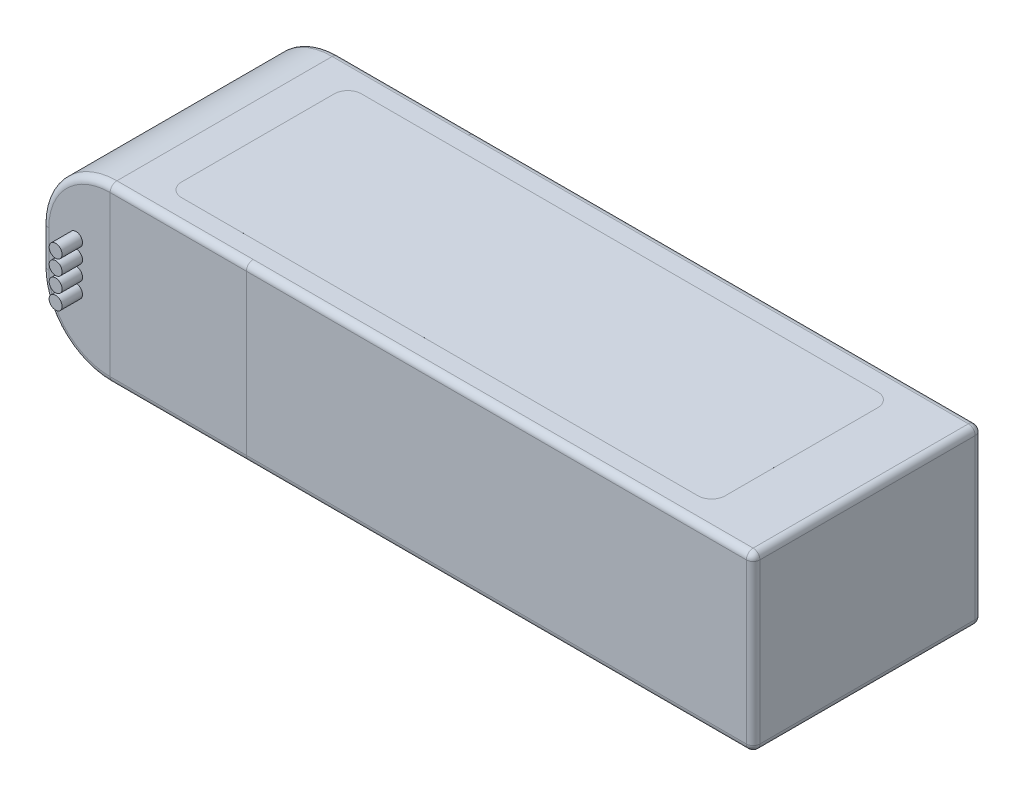
from build123d import *

# Parameters (mm, degrees)
SKETCH1_W           = 104.4
SKETCH1_H           = 33.6
BOSS_EXTRUDE1_DEPTH = 12.7
FILLET1_R           = 10
SKETCH2_R           = 1.9
BOSS_EXTRUDE2_DEPTH = 5
SKETCH4_R           = 0.95
BOSS_EXTRUDE3_DEPTH = 3
SKETCH5_W           = 20
SKETCH5_H           = 25.4
BOSS_EXTRUDE4_DEPTH = 0.0001
BOSS_EXTRUDE5_DEPTH = 0.0001
BOSS_EXTRUDE6_DEPTH = 0.0001
FILLET7_R           = 1
FILLET8_R           = 1


with BuildPart() as part:
    # Sketch1 → Boss-Extrude1 (new body, symmetric)
    with BuildSketch(Plane(origin=(0, 0, 0), x_dir=(1, 0, 0), z_dir=(0, 1, 0))):
        Rectangle(SKETCH1_W, SKETCH1_H)
    extrude(amount=BOSS_EXTRUDE1_DEPTH, both=True)

    # Fillet1
    fillet1_edges = [part.edges().sort_by_distance(p)[0] for p in [
        (-52.2, 12.7, 0),
        (-52.2, -12.7, 0),
    ]]
    fillet(fillet1_edges, radius=FILLET1_R)

    # Sketch2 → Boss-Extrude2 (add)
    with BuildSketch(Plane(origin=(0, 0, -16.8), x_dir=(-1, 0, 0), z_dir=(0, 0, -1))):
        with Locations((44.2, 3.35)):
            Circle(SKETCH2_R)
        with Locations((44.2, -3.35)):
            Circle(SKETCH2_R)
    extrude(amount=BOSS_EXTRUDE2_DEPTH)

    # Sketch4 → Boss-Extrude3 (add)
    with BuildSketch(Plane.XY.offset(16.8)):
        with Locations((-47.2, 3.3)):
            Circle(SKETCH4_R)
        with Locations((-47.2, 1.1)):
            Circle(SKETCH4_R)
        with Locations((-47.2, -1.1)):
            Circle(SKETCH4_R)
        with Locations((-47.2, -3.3)):
            Circle(SKETCH4_R)
    extrude(amount=BOSS_EXTRUDE3_DEPTH)

    # Sketch5 → Boss-Extrude4 (add)
    with BuildSketch(Plane.XY.offset(16.8)):
        with Locations((-32.2, 0)):
            Rectangle(SKETCH5_W, SKETCH5_H)
    boss_extrude4 = extrude(amount=BOSS_EXTRUDE4_DEPTH)

    # Mirror1: Boss-Extrude4 across plane
    add(boss_extrude4.mirror(Plane.XY))

    # Mirror1 at the second plane: Boss-Extrude4 across plane
    add(boss_extrude4.mirror(Plane.ZX))

    # Sketch6 → Boss-Extrude5 (add)
    with BuildSketch(Plane(origin=(0, 12.7, 0), x_dir=(1, 0, 0), z_dir=(0, 1, 0))):
        with BuildLine():
            Line((-35.3, 13.2), (40.5, 13.2))
            ThreePointArc((40.5, 13.2), (41.914213562, 12.614213562), (42.5, 11.2))
            Line((42.5, 11.2), (42.5, -11.2))
            ThreePointArc((42.5, -11.2), (41.914213562, -12.614213562), (40.5, -13.2))
            Line((40.5, -13.2), (-35.3, -13.2))
            ThreePointArc((-35.3, -13.2), (-36.714213562, -12.614213562), (-37.3, -11.2))
            Line((-37.3, -11.2), (-37.3, 11.2))
            ThreePointArc((-37.3, 11.2), (-36.714213562, 12.614213562), (-35.3, 13.2))
        make_face()
    extrude(amount=BOSS_EXTRUDE5_DEPTH)

    # Sketch7 → Boss-Extrude6 (add)
    with BuildSketch(Plane.XZ.offset(12.7)):
        with BuildLine():
            Line((-23.4, 12.5), (27.5, 12.5))
            ThreePointArc((27.5, 12.5), (28.914213562, 11.914213562), (29.5, 10.5))
            Line((29.5, 10.5), (29.5, -10.5))
            ThreePointArc((29.5, -10.5), (28.914213562, -11.914213562), (27.5, -12.5))
            Line((27.5, -12.5), (-23.4, -12.5))
            ThreePointArc((-23.4, -12.5), (-24.814213562, -11.914213562), (-25.4, -10.5))
            Line((-25.4, -10.5), (-25.4, 10.5))
            ThreePointArc((-25.4, 10.5), (-24.814213562, 11.914213562), (-23.4, 12.5))
        make_face()
    extrude(amount=BOSS_EXTRUDE6_DEPTH)

    # Fillet7
    fillet7_edges = [part.edges().sort_by_distance(p)[0] for p in [
        (52.2, 12.7, 0),
        (-52.2, 0, 16.8),
        (-52.2, 0, -16.8),
        (15, 12.7, -16.8),
        (-49.271067812, 9.771067812, 16.8),
        (-49.271067812, -9.771067812, 16.8),
        (-49.271067812, 9.771067812, -16.8),
        (-49.271067812, -9.771067812, -16.8),
        (15, -12.7, -16.8),
        (52.2, -12.7, 0),
        (15, -12.7, 16.8),
        (15, 12.7, 16.8),
        (52.2, 0, -16.8),
        (52.2, 0, 16.8),
    ]]
    fillet(fillet7_edges, radius=FILLET7_R)

    # Fillet8
    fillet8_edges = [part.edges().sort_by_distance(p)[0] for p in [
        (-32.2, -12.7, 16.8001),
        (-32.2, 12.7, 16.8001),
        (-32.2, 12.7, -16.8001),
        (-32.2, -12.7, -16.8001),
    ]]
    fillet(fillet8_edges, radius=FILLET8_R)


solid = part.part
